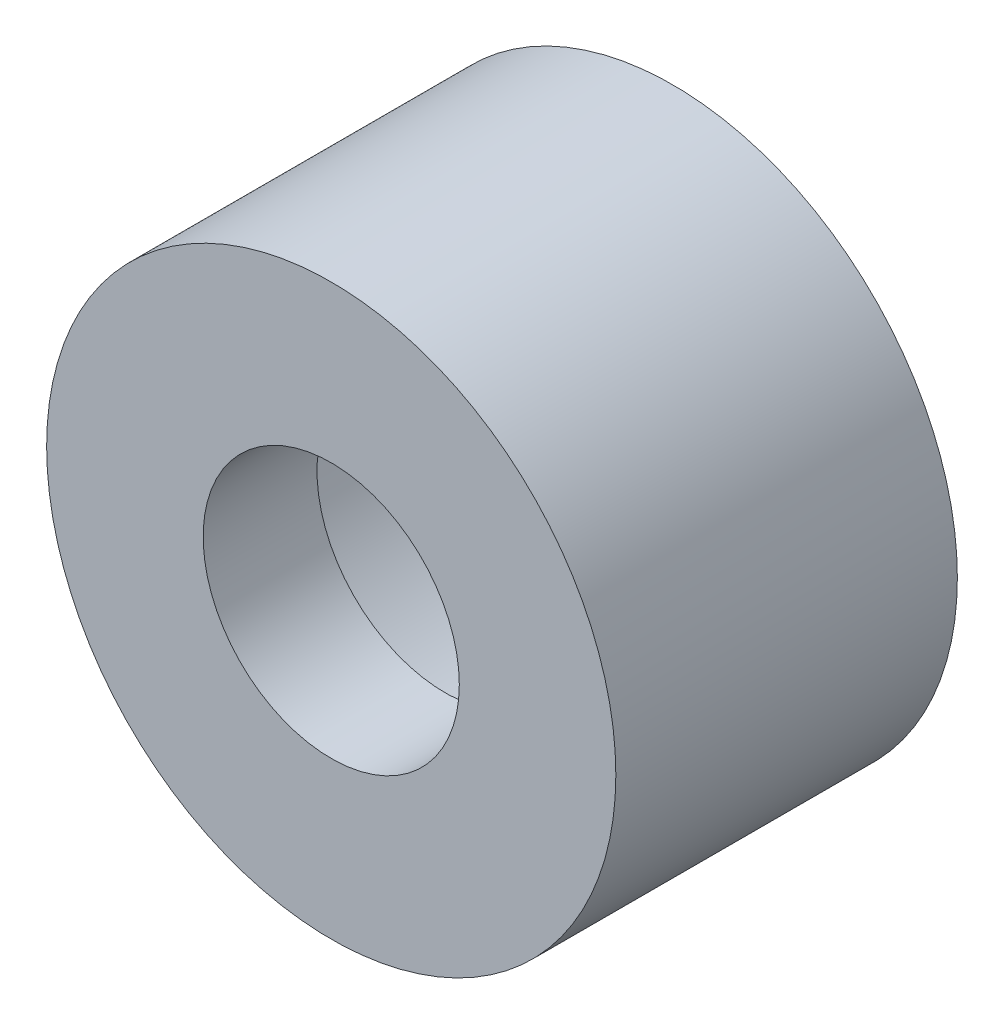
from build123d import *

# Parameters (mm, degrees)
CROQUIS1_R              = 5
CROQUIS1_R_2            = 4.25
SALIENTE_EXTRUIR1_DEPTH = 4
CROQUIS2_R              = 5
CROQUIS2_R_2            = 2.25
SALIENTE_EXTRUIR2_DEPTH = 2


with BuildPart() as part:
    # Croquis1 → Saliente-Extruir1 (new body)
    with BuildSketch(Plane.XY):
        Circle(CROQUIS1_R)
        Circle(CROQUIS1_R_2, mode=Mode.SUBTRACT)
    extrude(amount=SALIENTE_EXTRUIR1_DEPTH)

    # Croquis2 → Saliente-Extruir2 (add)
    with BuildSketch(Plane.XY.offset(4)):
        Circle(CROQUIS2_R)
        Circle(CROQUIS2_R_2, mode=Mode.SUBTRACT)
    extrude(amount=SALIENTE_EXTRUIR2_DEPTH)


solid = part.part
